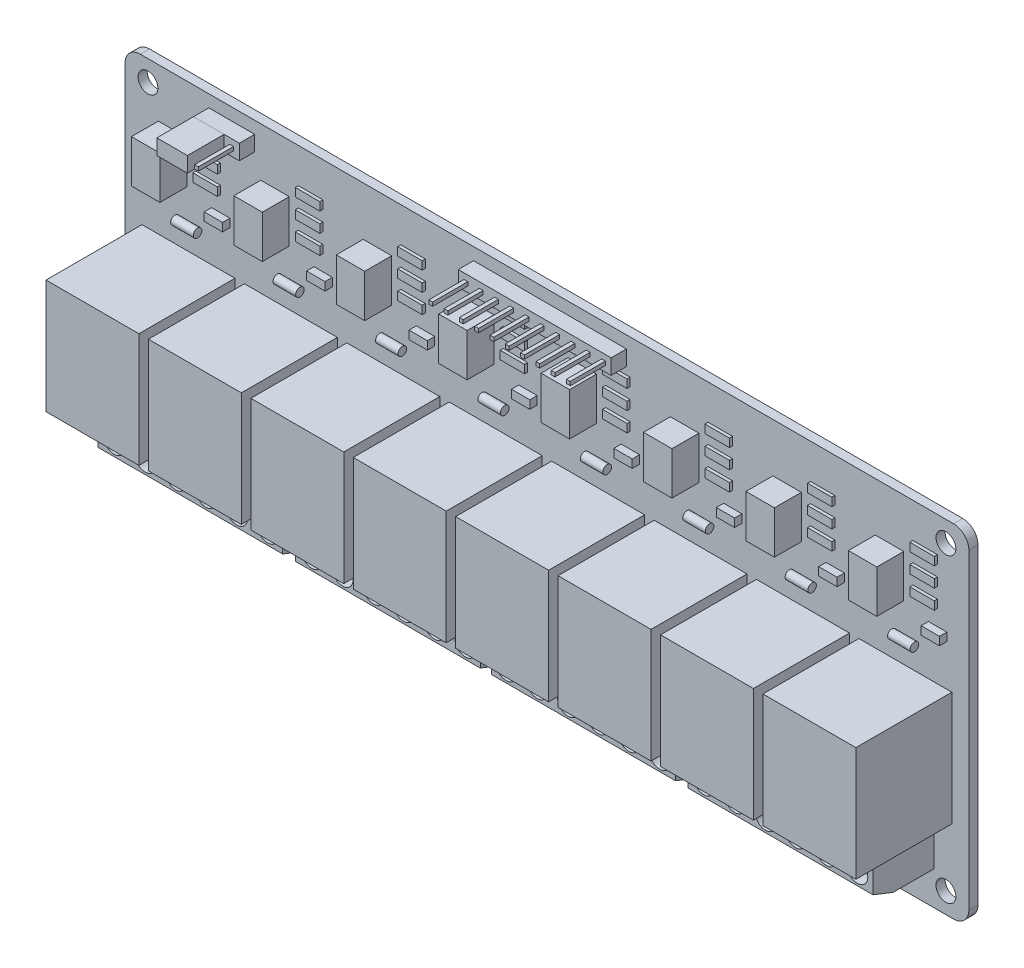
from build123d import *

# Parameters (mm, degrees)
SKETCH1_W               = 138
SKETCH1_H               = 56
SKETCH1_R               = 1.625
BOSS_EXTRUDE1_DEPTH     = 1.5
FILLET1_R               = 2.5
SKETCH2_W               = 15.2
SKETCH2_H               = 18.65
BOSS_EXTRUDE2_DEPTH     = 15.7
SKETCH3_W               = 4.65
SKETCH3_H               = 7
BOSS_EXTRUDE3_DEPTH     = 4.4
BOSS_EXTRUDE4_START     = -8.2
SKETCH4_R               = 0.7
BOSS_EXTRUDE4_DEPTH     = 3.7
SKETCH5_W               = 3
SKETCH5_H               = 1.35
BOSS_EXTRUDE5_DEPTH     = 1.2
SKETCH6_W               = 4
SKETCH6_H               = 1.35
BOSS_EXTRUDE6_DEPTH     = 0.5
LPATTERN1_COUNT         = 8
LPATTERN1_PITCH         = 16.75
BOSS_EXTRUDE7_START     = -5.675
BOSS_EXTRUDE7_DEPTH     = 126.75
SKETCH8_W               = 1.8
SKETCH8_H               = 10
SKETCH8_W_2             = 2.1
CUT_EXTRUDE1_DEPTH      = 7
SKETCH9_R               = 1.7
CUT_EXTRUDE2_DEPTH      = 2
MIRROR2_COPY_1_SKETCH_R = 1.7
MIRROR2_COPY_1_DEPTH    = 2
SKETCH11_W              = 2.5
SKETCH11_H              = 2.5
BOSS_EXTRUDE9_DEPTH     = 2.5
SKETCH12_W              = 0.62
SKETCH12_H              = 0.62
BOSS_EXTRUDE10_DEPTH    = 5.75
LPATTERN2_COUNT         = 3
LPATTERN2_PITCH         = 2.5
SKETCH13_W              = 5
SKETCH13_H              = 2.5
BOSS_EXTRUDE11_DEPTH    = 6
SKETCH15_W              = 2.5
SKETCH15_H              = 2.5
BOSS_EXTRUDE12_DEPTH    = 2.5
SKETCH16_W              = 0.62
SKETCH16_H              = 0.62
BOSS_EXTRUDE13_DEPTH    = 5.75
LPATTERN5_COUNT         = 10
LPATTERN5_PITCH         = 2.5


with BuildPart() as part:
    # Sketch1 → Boss-Extrude1 (new body)
    with BuildSketch(Plane.XY):
        Rectangle(SKETCH1_W, SKETCH1_H)
        with Locations((-65.25, 24.625)):
            Circle(SKETCH1_R, mode=Mode.SUBTRACT)
        with Locations((-65.25, -24.625)):
            Circle(SKETCH1_R, mode=Mode.SUBTRACT)
        with Locations((65.25, -24.625)):
            Circle(SKETCH1_R, mode=Mode.SUBTRACT)
        with Locations((65.25, 24.625)):
            Circle(SKETCH1_R, mode=Mode.SUBTRACT)
    extrude(amount=BOSS_EXTRUDE1_DEPTH)

    # Fillet1
    fillet1_edges = [part.edges().sort_by_distance(p)[0] for p in [
        (-69, 28, 0.75),
        (69, 28, 0.75),
        (69, -28, 0.75),
        (-69, -28, 0.75),
    ]]
    fillet(fillet1_edges, radius=FILLET1_R)

    # Sketch2 → Boss-Extrude2 (add)
    with BuildSketch(Plane.XY.offset(1.5)):
        with Locations((58.625, -5.325)):
            Rectangle(SKETCH2_W, SKETCH2_H)
    boss_extrude2 = extrude(amount=BOSS_EXTRUDE2_DEPTH)

    # Sketch3 → Boss-Extrude3 (add)
    with BuildSketch(Plane.XY.offset(1.5)):
        with Locations((56.025, 16.5)):
            Rectangle(SKETCH3_W, SKETCH3_H)
    boss_extrude3 = extrude(amount=BOSS_EXTRUDE3_DEPTH)

    # Sketch4 → Boss-Extrude4 (add)
    with BuildSketch(Plane(origin=(69, 0, 0), x_dir=(0, 0, -1), z_dir=(1, 0, 0)).offset(BOSS_EXTRUDE4_START)):
        with Locations((-2.19, 8.05)):
            Circle(SKETCH4_R)
    boss_extrude4 = extrude(amount=-BOSS_EXTRUDE4_DEPTH)

    # Sketch5 → Boss-Extrude5 (add)
    with BuildSketch(Plane.XY.offset(1.5)):
        with Locations((63.9, 11.425)):
            Rectangle(SKETCH5_W, SKETCH5_H)
    boss_extrude5 = extrude(amount=BOSS_EXTRUDE5_DEPTH)

    # Sketch6 → Boss-Extrude6 (add)
    with BuildSketch(Plane.XY.offset(1.5)):
        with Locations((61.85, 15.325)):
            Rectangle(SKETCH6_W, SKETCH6_H)
        with Locations((61.85, 18.475)):
            Rectangle(SKETCH6_W, SKETCH6_H)
        with Locations((61.85, 21.625)):
            Rectangle(SKETCH6_W, SKETCH6_H)
    boss_extrude6 = extrude(amount=BOSS_EXTRUDE6_DEPTH)

    # LPattern1: Boss-Extrude2, Boss-Extrude3, Boss-Extrude4, Boss-Extrude5, Boss-Extrude6 ×8
    with Locations(*[(-i * LPATTERN1_PITCH, 0, 0) for i in range(1, LPATTERN1_COUNT)]):
        add(boss_extrude2)
        add(boss_extrude3)
        add(boss_extrude4)
        add(boss_extrude5)
        add(boss_extrude6)

    # Sketch7 → Boss-Extrude7 (add)
    with BuildSketch(Plane(origin=(69, 0, 0), x_dir=(0, 0, -1), z_dir=(1, 0, 0)).offset(BOSS_EXTRUDE7_START)):
        Polygon((-1.5, -15.45), (-8.2, -15.45), (-11.5, -17.05), (-11.5, -21.15), (-8.2, -22.45), (-1.5, -22.45), align=None)
    extrude(amount=-BOSS_EXTRUDE7_DEPTH)

    # Sketch8 → Cut-Extrude1 (cut)
    with BuildSketch(Plane.XZ.offset(22.45)):
        with Locations((0, 6.5)):
            Rectangle(SKETCH8_W, SKETCH8_H)
        with Locations((-32.1625, 6.5)):
            Rectangle(SKETCH8_W_2, SKETCH8_H)
        with Locations((32.0625, 6.5)):
            Rectangle(SKETCH8_W_2, SKETCH8_H)
    extrude(amount=-CUT_EXTRUDE1_DEPTH, mode=Mode.SUBTRACT)

    # Sketch9 → Cut-Extrude2 (cut)
    with BuildSketch(Plane.XY.offset(11.5)):
        with Locations((60.775, -19.1)):
            Circle(SKETCH9_R)
        with Locations((55.725, -19.1)):
            Circle(SKETCH9_R)
        with Locations((50.675, -19.1)):
            Circle(SKETCH9_R)
        with Locations((45.7625, -19.1)):
            Circle(SKETCH9_R)
        with Locations((40.7125, -19.1)):
            Circle(SKETCH9_R)
        with Locations((35.6625, -19.1)):
            Circle(SKETCH9_R)
    cut_extrude2 = extrude(amount=-CUT_EXTRUDE2_DEPTH, mode=Mode.SUBTRACT)

    # Mirror1: Cut-Extrude2 across plane
    add(cut_extrude2.mirror(Plane(origin=(32.0625, 0, 0), x_dir=(0, 0, 1), z_dir=(1, 0, 0))), mode=Mode.SUBTRACT)

    # Mirror2: Cut-Extrude2 across plane
    add(cut_extrude2.mirror(Plane(origin=(0, 0, 0), x_dir=(0, 0, 1), z_dir=(1, 0, 0))), mode=Mode.SUBTRACT)

    # Mirror2 copy 1 sketch → Mirror2 copy 1 (cut)
    with BuildSketch(Plane(origin=(-64.125, 0, 11.5), x_dir=(1, 0, 0), z_dir=(0, 0, 1))):
        with Locations((60.775, -19.1)):
            Circle(MIRROR2_COPY_1_SKETCH_R)
        with Locations((55.725, -19.1)):
            Circle(MIRROR2_COPY_1_SKETCH_R)
        with Locations((50.675, -19.1)):
            Circle(MIRROR2_COPY_1_SKETCH_R)
        with Locations((45.7625, -19.1)):
            Circle(MIRROR2_COPY_1_SKETCH_R)
        with Locations((40.7125, -19.1)):
            Circle(MIRROR2_COPY_1_SKETCH_R)
        with Locations((35.6625, -19.1)):
            Circle(MIRROR2_COPY_1_SKETCH_R)
    extrude(amount=-MIRROR2_COPY_1_DEPTH, mode=Mode.SUBTRACT)

    # Sketch11 → Boss-Extrude9 (add)
    with BuildSketch(Plane.XY.offset(1.5)):
        with Locations((-54.05, 24.75)):
            Rectangle(SKETCH11_W, SKETCH11_H)
    boss_extrude9 = extrude(amount=BOSS_EXTRUDE9_DEPTH)

    # Sketch12 → Boss-Extrude10 (add)
    with BuildSketch(Plane.XY.offset(4)):
        with Locations((-54.05, 24.75)):
            Rectangle(SKETCH12_W, SKETCH12_H)
    boss_extrude10 = extrude(amount=BOSS_EXTRUDE10_DEPTH)

    # LPattern2: Boss-Extrude9, Boss-Extrude10 ×3
    with Locations(*[(i * LPATTERN2_PITCH, 0, 0) for i in range(1, LPATTERN2_COUNT)]):
        add(boss_extrude9)
        add(boss_extrude10)

    # Sketch15 → Boss-Extrude12 (add)
    with BuildSketch(Plane.XY.offset(1.5)):
        with Locations((11.75, 24.75)):
            Rectangle(SKETCH15_W, SKETCH15_H)
    boss_extrude12 = extrude(amount=BOSS_EXTRUDE12_DEPTH)

    # Sketch16 → Boss-Extrude13 (add)
    with BuildSketch(Plane.XY.offset(4)):
        with Locations((11.75, 24.75)):
            Rectangle(SKETCH16_W, SKETCH16_H)
    boss_extrude13 = extrude(amount=BOSS_EXTRUDE13_DEPTH)

    # LPattern5: Boss-Extrude12, Boss-Extrude13 ×10
    with Locations(*[(-i * LPATTERN5_PITCH, 0, 0) for i in range(1, LPATTERN5_COUNT)]):
        add(boss_extrude12)
        add(boss_extrude13)


with BuildPart() as body_2:
    # Sketch13 → Boss-Extrude11 (new body)
    with BuildSketch(Plane.XY.offset(4)):
        with Locations((-52.8, 24.75)):
            Rectangle(SKETCH13_W, SKETCH13_H)
    extrude(amount=BOSS_EXTRUDE11_DEPTH)


solid = Compound([part.part, body_2.part])
